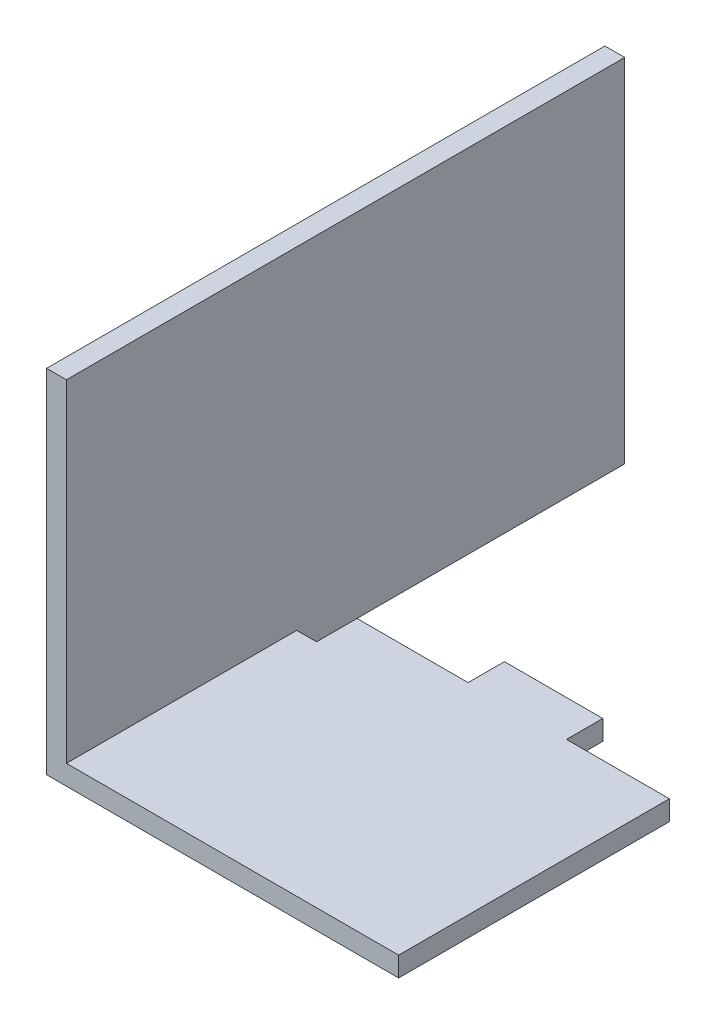
from build123d import *

# Parameters (mm, degrees)
EXTRUDE1_DEPTH     = 40
CUT_EXTRUDE3_DEPTH = 2.42


with BuildPart() as part:
    # Sketch1 → Extrude1 (new body)
    with BuildSketch(Plane.XY):
        Polygon((0, 0), (0, -25.22), (25.22, -25.22), (25.22, -23.8), (1.42, -23.8), (1.42, 0), align=None)
    extrude(amount=EXTRUDE1_DEPTH)

    # Sketch3 → Cut-Extrude3 (cut, through all)
    with BuildSketch(Plane(origin=(0, -23.8, 0), x_dir=(-1, 0, 0), z_dir=(0, 1, 0))):
        Polygon((-25.22, 0), (-25.22, 20.6), (-17.85, 20.6), (-17.85, 18), (-10.8, 18), (-10.8, 20.6), (-2.84, 20.6), (-2.84, 23.5), (-1.42, 23.5), (-1.42, 0), align=None)
    extrude(amount=-CUT_EXTRUDE3_DEPTH, mode=Mode.SUBTRACT)


solid = part.part
